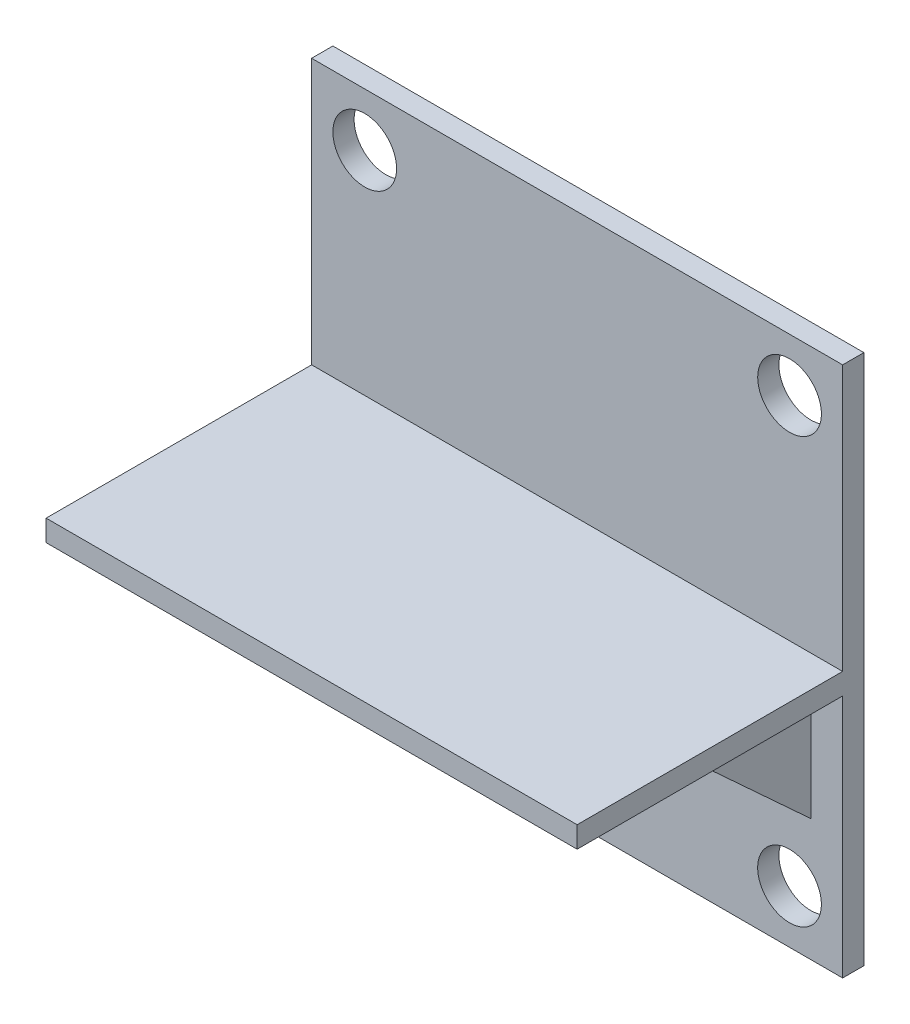
from build123d import *

# Parameters (mm, degrees)
SKETCH1_W                = 250
SKETCH1_H                = 250
BOSS_EXTRUDE1_DEPTH      = 10
SKETCH2_R                = 15
CUT_EXTRUDE1_DEPTH       = 10
SKETCH3_W                = 125
SKETCH3_H                = 10
BOSS_EXTRUDE2_DEPTH      = 250
BOSS_EXTRUDE3_DEPTH      = 10
BOSS_EXTRUDE4_DEPTH      = 10
BOSS_EXTRUDE4_DEPTH_BACK = 10


with BuildPart() as part:
    # Sketch1 → Boss-Extrude1 (new body)
    with BuildSketch(Plane.XY):
        with Locations((28.899957468, -24.872643547)):
            Rectangle(SKETCH1_W, SKETCH1_H)
    extrude(amount=BOSS_EXTRUDE1_DEPTH)

    # Sketch2 → Cut-Extrude1 (cut)
    with BuildSketch(Plane.XY.offset(10)):
        with Locations((-71.100042532, 75.127356453)):
            Circle(SKETCH2_R)
        with Locations((128.899957468, 75.127356453)):
            Circle(SKETCH2_R)
        with Locations((128.899957468, -124.872643547)):
            Circle(SKETCH2_R)
        with Locations((-71.100042532, -124.872643547)):
            Circle(SKETCH2_R)
    extrude(amount=-CUT_EXTRUDE1_DEPTH, mode=Mode.SUBTRACT)

    # Sketch3 → Boss-Extrude2 (add)
    with BuildSketch(Plane.ZY.offset(96.100042532)):
        with Locations((72.5, -29.872643547)):
            Rectangle(SKETCH3_W, SKETCH3_H)
    extrude(amount=-BOSS_EXTRUDE2_DEPTH)

    # Sketch4 → Boss-Extrude3 (add)
    with BuildSketch(Plane.ZY.offset(71.100042532)):
        Polygon((72.5, -34.872643547), (10, -92.372643547), (10, -34.872643547), align=None)
    boss_extrude3 = extrude(amount=BOSS_EXTRUDE3_DEPTH)

    # Mirror1: Boss-Extrude3 across plane
    add(boss_extrude3.mirror(Plane.ZY.offset(-28.899957468)))

    # Sketch5 → Boss-Extrude4 (add, two sides: drawn at the far end of the back side and taken through both)
    with BuildSketch(Plane.ZY.offset(-28.899957468).offset(-BOSS_EXTRUDE4_DEPTH_BACK)):
        with BuildLine():
            ThreePointArc((10, -95.883227708), (10.67430488, -92.668544051), (12.583547753, -89.995779614))
            Line((12.583547753, -89.995779614), (70.203747928, -36.985195453))
            ThreePointArc((70.203747928, -36.985195453), (72.713276092, -35.419470238), (75.620200175, -34.872643547))
            Line((75.620200175, -34.872643547), (10, -34.872643547))
            Line((10, -34.872643547), (10, -95.883227708))
        make_face()
    extrude(amount=BOSS_EXTRUDE4_DEPTH + BOSS_EXTRUDE4_DEPTH_BACK)


solid = part.part
